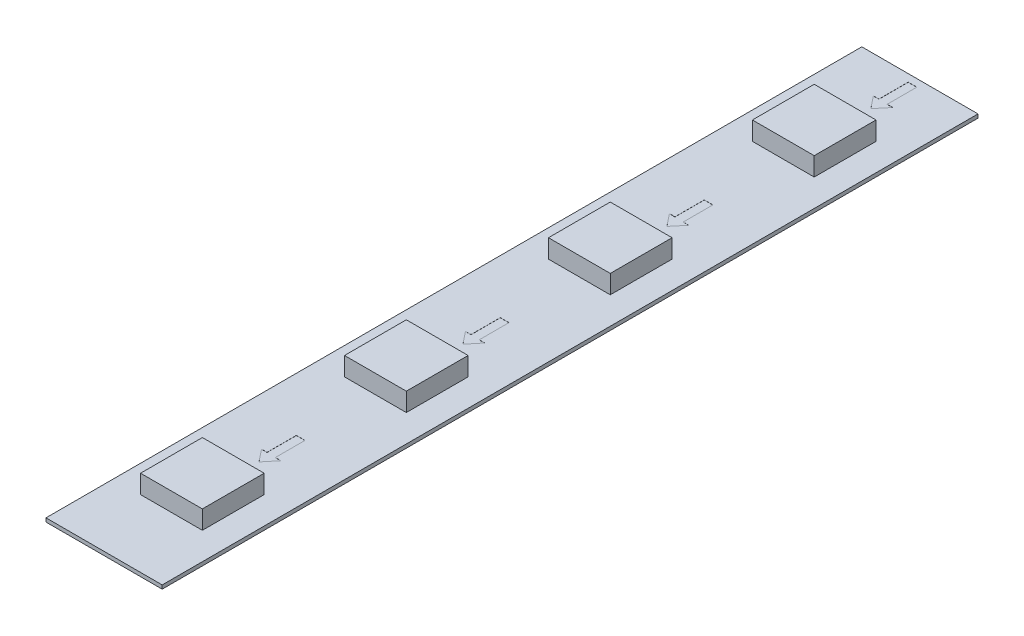
from build123d import *

# Parameters (mm, degrees)
SKETCH1_W           = 9.4
SKETCH1_H           = 16.5
BOSS_EXTRUDE1_DEPTH = 0.3
SKETCH2_W           = 5
SKETCH2_H           = 5
BOSS_EXTRUDE2_DEPTH = 1.5
CUT_EXTRUDE1_DEPTH  = 0.01
LPATTERN1_COUNT     = 4
LPATTERN1_PITCH     = 16.5


with BuildPart() as part:
    # Sketch1 → Boss-Extrude1 (new body)
    with BuildSketch(Plane(origin=(0, 0, 0), x_dir=(1, 0, 0), z_dir=(0, 1, 0))):
        Rectangle(SKETCH1_W, SKETCH1_H)
    boss_extrude1 = extrude(amount=BOSS_EXTRUDE1_DEPTH)

    # Sketch2 → Boss-Extrude2 (add)
    with BuildSketch(Plane(origin=(0, 0.3, 0), x_dir=(1, 0, 0), z_dir=(0, 1, 0))):
        with Locations((0, -0.3)):
            Rectangle(SKETCH2_W, SKETCH2_H)
    boss_extrude2 = extrude(amount=BOSS_EXTRUDE2_DEPTH)

    # Sketch3 → Cut-Extrude1 (cut)
    with BuildSketch(Plane(origin=(0, 0.3, 0), x_dir=(1, 0, 0), z_dir=(0, 1, 0))):
        Polygon((-0.34778048, 5.281417879), (-0.79778048, 5.281417879), (0, 4.281417879), (0.80221952, 5.251170562), (0.35221952, 5.251170562), (0.35221952, 7.651170562), (-0.34778048, 7.651170562), align=None)
    cut_extrude1 = extrude(amount=-CUT_EXTRUDE1_DEPTH, mode=Mode.SUBTRACT)

    # LPattern1: Boss-Extrude1, Boss-Extrude2, Cut-Extrude1 ×4
    with Locations(*[(0, 0, i * LPATTERN1_PITCH) for i in range(1, LPATTERN1_COUNT)]):
        add(boss_extrude1)
        add(boss_extrude2)
        add(cut_extrude1, mode=Mode.SUBTRACT)


solid = part.part
